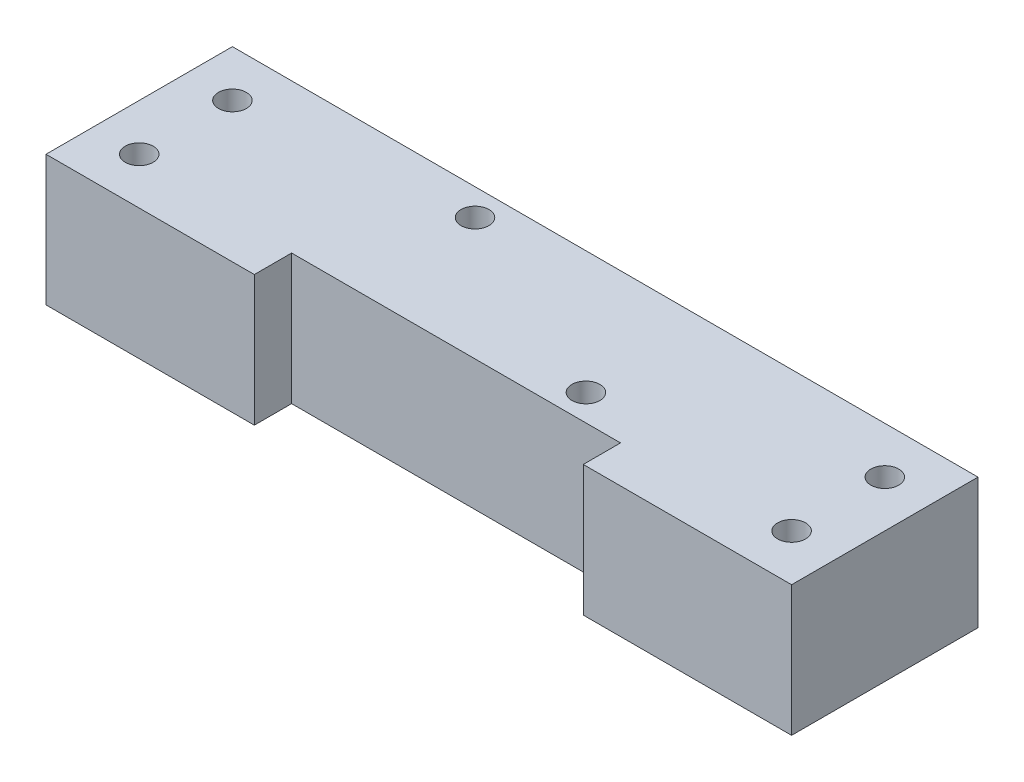
from build123d import *

# Parameters (mm, degrees)
SKETCH1_W           = 80
SKETCH1_H           = 14
BOSS_EXTRUDE1_DEPTH = 20
SKETCH2_W           = 35.292
SKETCH2_H           = 14
CUT_EXTRUDE1_DEPTH  = 4
SKETCH3_R           = 1.5
CUT_EXTRUDE2_DEPTH  = 14
SKETCH4_R           = 1.5
CUT_EXTRUDE3_DEPTH  = 8


with BuildPart() as part:
    # Sketch1 → Boss-Extrude1 (new body)
    with BuildSketch(Plane.XY):
        with Locations((40, 7)):
            Rectangle(SKETCH1_W, SKETCH1_H)
    extrude(amount=BOSS_EXTRUDE1_DEPTH)

    # Sketch2 → Cut-Extrude1 (cut)
    with BuildSketch(Plane.XY.offset(20)):
        with Locations((40, 7)):
            Rectangle(SKETCH2_W, SKETCH2_H)
    extrude(amount=-CUT_EXTRUDE1_DEPTH, mode=Mode.SUBTRACT)

    # Sketch3 → Cut-Extrude2 (cut)
    with BuildSketch(Plane(origin=(0, 14, 0), x_dir=(1, 0, 0), z_dir=(0, 1, 0))):
        with Locations((5, -5)):
            Circle(SKETCH3_R)
        with Locations((5, -15)):
            Circle(SKETCH3_R)
        with Locations((75, -15)):
            Circle(SKETCH3_R)
        with Locations((75, -5)):
            Circle(SKETCH3_R)
    extrude(amount=-CUT_EXTRUDE2_DEPTH, mode=Mode.SUBTRACT)

    # Sketch4 → Cut-Extrude3 (cut)
    with BuildSketch(Plane(origin=(0, 14, 0), x_dir=(1, 0, 0), z_dir=(0, 1, 0))):
        with Locations((28.9, -2.87)):
            Circle(SKETCH4_R)
        with Locations((51.1, -13.17)):
            Circle(SKETCH4_R)
    extrude(amount=-CUT_EXTRUDE3_DEPTH, mode=Mode.SUBTRACT)


solid = part.part
